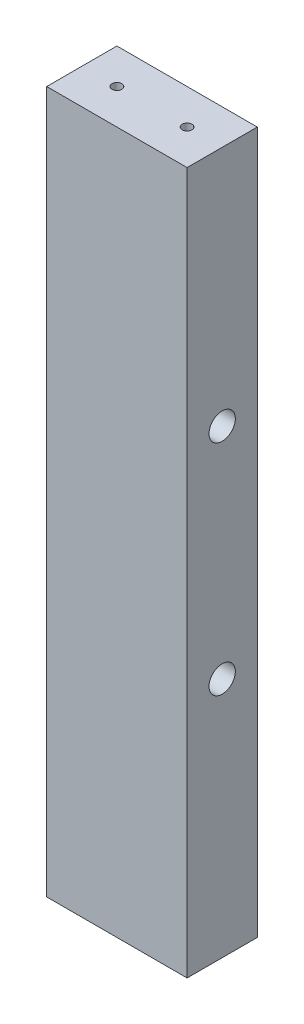
from build123d import *

# Parameters (mm, degrees)
SKETCH2_W                 = 25.4
SKETCH2_H                 = 127
BOSS_EXTRUDE1_DEPTH       = 6.35
SKETCH3_R                 = 1.190625
CUT_EXTRUDE2_DEPTH        = 26.4
SKETCH3_4_R               = 2.38125
SKETCH3_4_R_2             = 1.190625
CUT_EXTRUDE3_DEPTH        = 9.525
F_2_56_TAPPED_HOLE1_D     = 1.778
F_2_56_TAPPED_HOLE1_DEPTH = 10.668
F_2_56_TAPPED_HOLE1_TIP   = 0.53416509
F_2_56_TAPPED_HOLE2_D     = 1.778
F_2_56_TAPPED_HOLE2_DEPTH = 10.668
F_2_56_TAPPED_HOLE2_TIP   = 0.53416509


with BuildPart() as part:
    # Sketch2 → Boss-Extrude1 (new body, symmetric)
    with BuildSketch(Plane.XY):
        Rectangle(SKETCH2_W, SKETCH2_H)
    extrude(amount=BOSS_EXTRUDE1_DEPTH, both=True)

    # Sketch3 → Cut-Extrude2 (cut, through all)
    with BuildSketch(Plane(origin=(12.7, 0, 0), x_dir=(0, 0, -1), z_dir=(1, 0, 0))):
        with Locations((0, 19.812)):
            Circle(SKETCH3_R)
        with Locations((0, -19.812)):
            Circle(SKETCH3_R)
    extrude(amount=-CUT_EXTRUDE2_DEPTH, mode=Mode.SUBTRACT)

    # Sketch3_4 → Cut-Extrude3 (cut)
    with BuildSketch(Plane(origin=(12.7, 0, 0), x_dir=(0, 0, -1), z_dir=(1, 0, 0))):
        with Locations((0, 19.812)):
            Circle(SKETCH3_4_R)
        with Locations((0, 19.812)):
            Circle(SKETCH3_4_R_2, mode=Mode.SUBTRACT)
        with Locations((0, -19.812)):
            Circle(SKETCH3_4_R)
        with Locations((0, -19.812)):
            Circle(SKETCH3_4_R_2, mode=Mode.SUBTRACT)
    extrude(amount=-CUT_EXTRUDE3_DEPTH, mode=Mode.SUBTRACT)

    # 2-56 Tapped Hole1
    with Locations(Plane(origin=(0, 63.5, 0), x_dir=(-1, 0, 0), z_dir=(0, 1, 0))):
        with Locations((6.35, 0), (-6.35, 0)):
            Hole(F_2_56_TAPPED_HOLE1_D / 2, depth=F_2_56_TAPPED_HOLE1_DEPTH)
            with Locations((0, 0, -(F_2_56_TAPPED_HOLE1_DEPTH + F_2_56_TAPPED_HOLE1_TIP / 2))):  # 118° drill point
                Cone(0, F_2_56_TAPPED_HOLE1_D / 2, F_2_56_TAPPED_HOLE1_TIP, mode=Mode.SUBTRACT)

    # 2-56 Tapped Hole2
    with Locations(Plane.XZ.offset(63.5)):
        with Locations((6.35, 0), (-6.35, 0)):
            Hole(F_2_56_TAPPED_HOLE2_D / 2, depth=F_2_56_TAPPED_HOLE2_DEPTH)
            with Locations((0, 0, -(F_2_56_TAPPED_HOLE2_DEPTH + F_2_56_TAPPED_HOLE2_TIP / 2))):  # 118° drill point
                Cone(0, F_2_56_TAPPED_HOLE2_D / 2, F_2_56_TAPPED_HOLE2_TIP, mode=Mode.SUBTRACT)


solid = part.part
